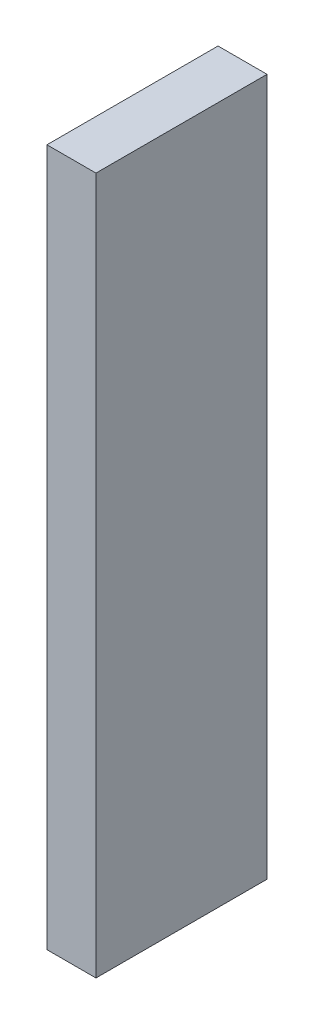
from build123d import *

# Parameters (mm, degrees)
SCHIZZO1_W                   = 4.5
SCHIZZO1_H                   = 64
ESTRUSIONE_ESTRUSIONE1_DEPTH = 15.707


with BuildPart() as part:
    # Schizzo1 → Estrusione-Estrusione1 (new body)
    with BuildSketch(Plane.XY):
        with Locations((2.25, 32)):
            Rectangle(SCHIZZO1_W, SCHIZZO1_H)
    extrude(amount=ESTRUSIONE_ESTRUSIONE1_DEPTH)


solid = part.part
